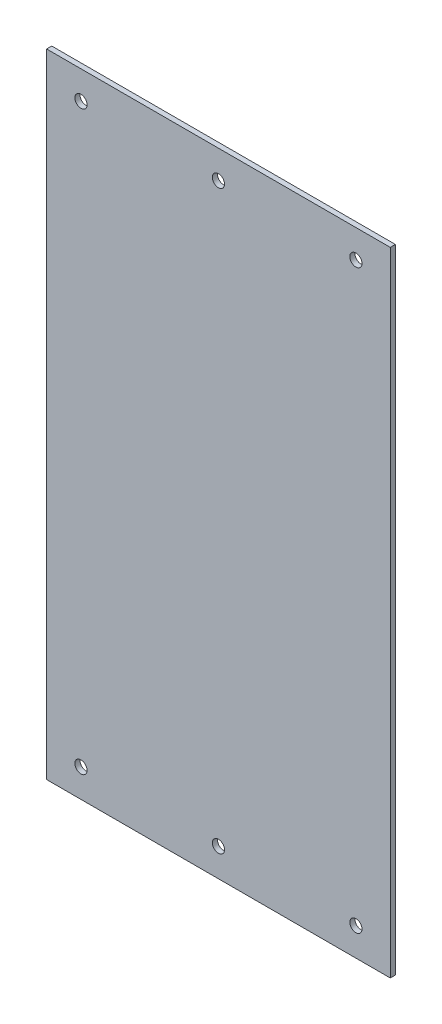
from build123d import *

# Parameters (mm, degrees)
SKETCH1_W            = 155
SKETCH1_H            = 285.39
BOSS_EXTRUDE1_DEPTH  = 2.305
M5_CLEARANCE_HOLE1_D = 5.5


with BuildPart() as part:
    # Sketch1 → Boss-Extrude1 (new body)
    with BuildSketch(Plane.XY):
        Rectangle(SKETCH1_W, SKETCH1_H)
    extrude(amount=BOSS_EXTRUDE1_DEPTH)

    # M5 Clearance Hole1 (through all)
    with Locations(Plane.XY.offset(2.305)):
        with Locations((-62, 129.995), (0, 129.995), (62, 129.995), (-62, -129.995), (0, -129.995), (62, -129.995)):
            Hole(M5_CLEARANCE_HOLE1_D / 2)


solid = part.part
